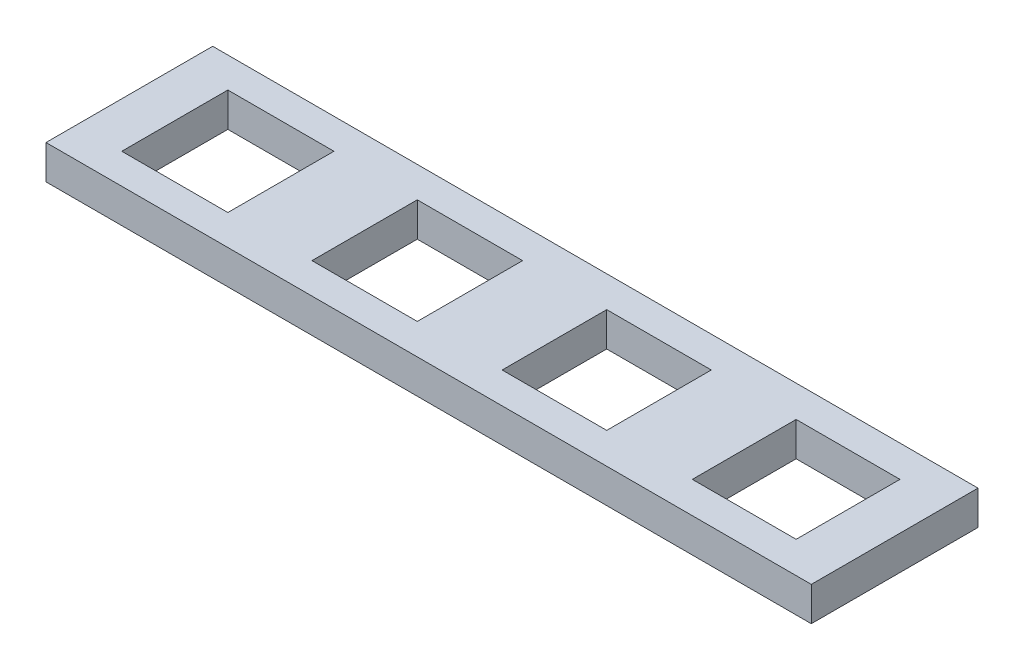
from build123d import *

# Parameters (mm, degrees)
SKETCH3_W           = 101
SKETCH3_H           = 22
SKETCH3_W_2         = 14
SKETCH3_H_2         = 14
SKETCH3_W_3         = 13.9
SKETCH3_H_3         = 13.9
SKETCH3_W_4         = 13.8
SKETCH3_H_4         = 13.8
SKETCH3_W_5         = 13.7
SKETCH3_H_5         = 13.7
BOSS_EXTRUDE5_DEPTH = 4.5


with BuildPart() as part:
    # Sketch3 → Boss-Extrude5 (new body)
    with BuildSketch(Plane(origin=(0, 0, 0), x_dir=(1, 0, 0), z_dir=(0, 1, 0))):
        with Locations((50.5, 11)):
            Rectangle(SKETCH3_W, SKETCH3_H)
        with Locations((13, 11)):
            Rectangle(SKETCH3_W_2, SKETCH3_H_2, mode=Mode.SUBTRACT)
        with Locations((38, 11)):
            Rectangle(SKETCH3_W_3, SKETCH3_H_3, mode=Mode.SUBTRACT)
        with Locations((63, 11)):
            Rectangle(SKETCH3_W_4, SKETCH3_H_4, mode=Mode.SUBTRACT)
        with Locations((88, 11)):
            Rectangle(SKETCH3_W_5, SKETCH3_H_5, mode=Mode.SUBTRACT)
    extrude(amount=BOSS_EXTRUDE5_DEPTH)


solid = part.part
